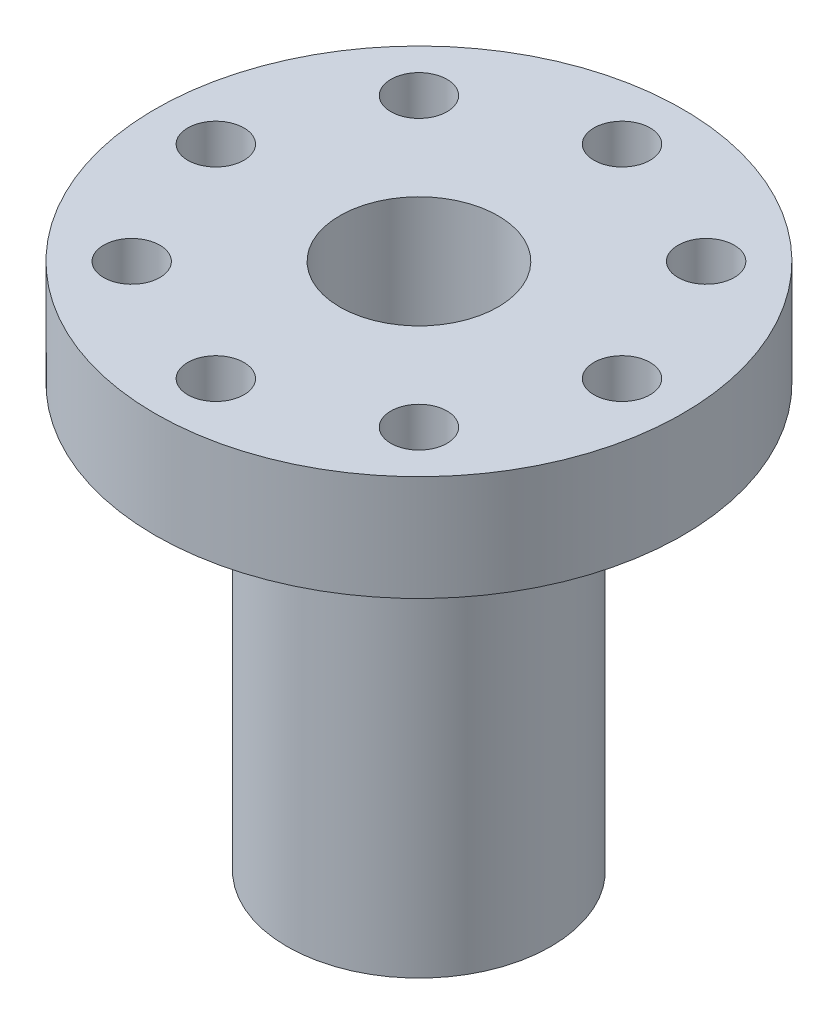
from build123d import *

# Parameters (mm, degrees)
CIRPATTERN1_COUNT  = 8
SKETCH5_R          = 3.81
CUT_EXTRUDE1_DEPTH = 20.828
SKETCH6_R          = 1.4986
CUT_EXTRUDE2_DEPTH = 5.572


with BuildPart() as part:
    # Sketch1 → Revolve1 (revolve)
    with BuildSketch(Plane.XY):
        Polygon((12.7, 0), (0, 0), (0, -25.4), (6.35, -25.4), (6.35, -5.08), (12.7, -5.08), align=None)
    revolve(axis=Axis((0, 0, 0), (0, -1, 0)))

    # Sketch4 → #6-32 Tapped Hole1 (revolve, cut)
    with BuildSketch(Plane(origin=(0, 0, 9.779), x_dir=(0, 0, 1), z_dir=(1, 0, 0))):
        Polygon((0, 0), (0, 10.21069403), (1.35255, 9.398), (1.35255, 0), align=None)
    f_6_32_tapped_hole1 = revolve(axis=Axis((0, 6.35, 9.779), (0, -1, 0)), mode=Mode.SUBTRACT)

    # CirPattern1: #6-32 Tapped Hole1 ×8 about axis
    cirpattern1_axis = Axis((0, 0, 0), (0, 1, 0))
    for i in range(1, CIRPATTERN1_COUNT):
        add(f_6_32_tapped_hole1.rotate(cirpattern1_axis, i * 360 / CIRPATTERN1_COUNT), mode=Mode.SUBTRACT)

    # Sketch5 → Cut-Extrude1 (cut)
    with BuildSketch(Plane(origin=(0, 0, 0), x_dir=(1, 0, 0), z_dir=(0, 1, 0))):
        Circle(SKETCH5_R)
    extrude(amount=-CUT_EXTRUDE1_DEPTH, mode=Mode.SUBTRACT)

    # Sketch6 → Cut-Extrude2 (cut, through all)
    with BuildSketch(Plane(origin=(0, -20.828, 0), x_dir=(1, 0, 0), z_dir=(0, 1, 0))):
        Circle(SKETCH6_R)
    extrude(amount=-CUT_EXTRUDE2_DEPTH, mode=Mode.SUBTRACT)


solid = part.part
